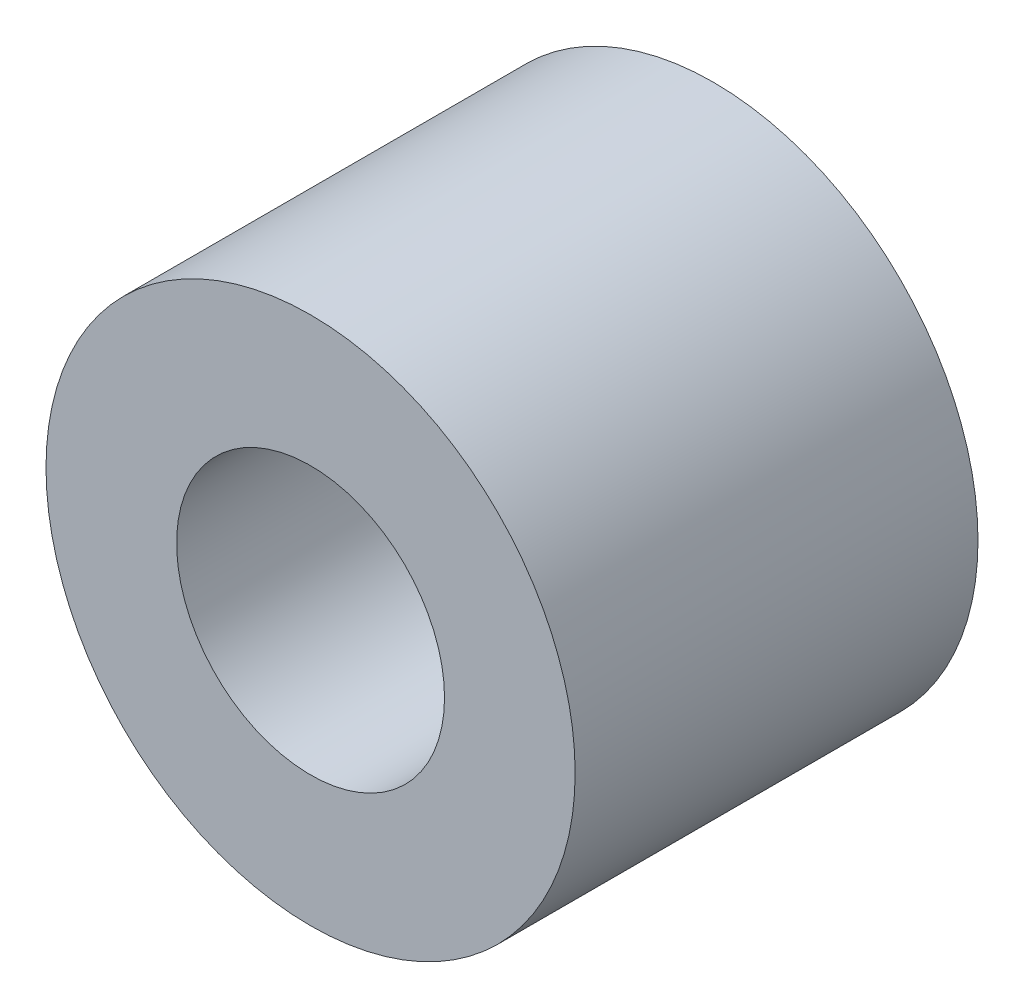
from build123d import *

# Parameters (mm, degrees)
SKETCH1_R              = 3.75
BOSS_EXTRUDE1_DEPTH    = 2.855
F_10_24_TAPPED_HOLE1_D = 3.7973


with BuildPart() as part:
    # Sketch1 → Boss-Extrude1 (new body, symmetric)
    with BuildSketch(Plane.XY):
        Circle(SKETCH1_R)
    extrude(amount=BOSS_EXTRUDE1_DEPTH, both=True)

    # #10-24 Tapped Hole1 (through all)
    with Locations(Plane.XY.offset(2.855)):
        with Locations((0, 0)):
            Hole(F_10_24_TAPPED_HOLE1_D / 2)


solid = part.part
